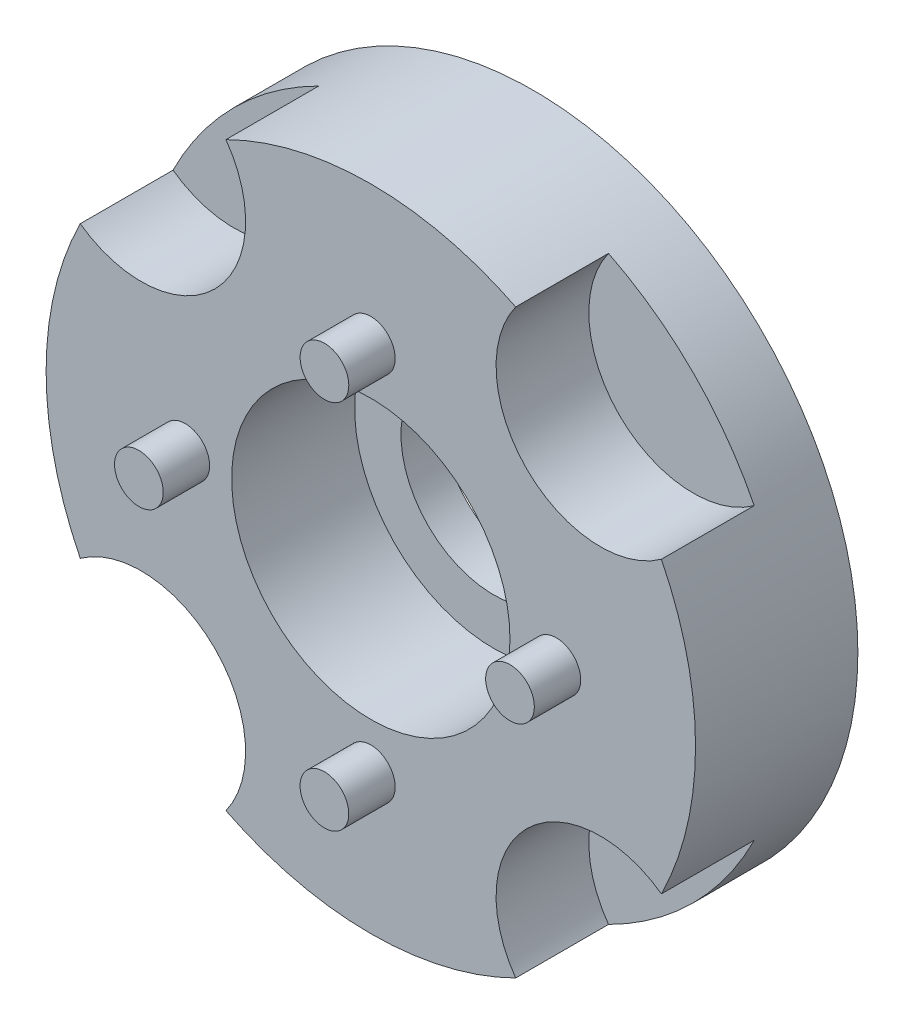
from build123d import *

# Parameters (mm, degrees)
SKIZZE1_R                            = 7
AUFSATZ_LINEAR_AUSTRAGEN1_DEPTH      = 3.5
SKIZZE2_R                            = 0.525
AUFSATZ_LINEAR_AUSTRAGEN2_DEPTH      = 1
KREISMUSTER1_COUNT                   = 4
SKIZZE3_R                            = 3
SCHNITT_LINEAR_AUSTRAGEN1_DEPTH      = 2
SCHNITT_LINEAR_AUSTRAGEN1_DEPTH_BACK = 2.65
SKIZZE4_R                            = 2
SCHNITT_LINEAR_AUSTRAGEN2_DEPTH      = 1.85
SKIZZE5_R                            = 2.25
SCHNITT_LINEAR_AUSTRAGEN3_DEPTH      = 2
KREISMUSTER2_COUNT                   = 4


with BuildPart() as part:
    # Skizze1 → Aufsatz-Linear austragen1 (new body)
    with BuildSketch(Plane.XY):
        Circle(SKIZZE1_R)
    extrude(amount=AUFSATZ_LINEAR_AUSTRAGEN1_DEPTH)

    # Skizze2 → Aufsatz-Linear austragen2 (add)
    with BuildSketch(Plane.XY.offset(3.5)):
        with Locations((0, 4)):
            Circle(SKIZZE2_R)
    aufsatz_linear_austragen2 = extrude(amount=AUFSATZ_LINEAR_AUSTRAGEN2_DEPTH)

    # Kreismuster1: Aufsatz-Linear austragen2 ×4 about axis
    kreismuster1_axis = Axis((0, 0, 0), (0, 0, 1))
    for i in range(1, KREISMUSTER1_COUNT):
        add(aufsatz_linear_austragen2.rotate(kreismuster1_axis, i * 360 / KREISMUSTER1_COUNT))

    # Skizze3 → Schnitt-Linear austragen1 (cut, two sides)
    with BuildSketch(Plane.XY.offset(3.5)) as schnitt_linear_austragen1_sk:
        Circle(SKIZZE3_R)
    extrude(amount=SCHNITT_LINEAR_AUSTRAGEN1_DEPTH, mode=Mode.SUBTRACT)
    extrude(schnitt_linear_austragen1_sk.sketch, amount=-SCHNITT_LINEAR_AUSTRAGEN1_DEPTH_BACK, mode=Mode.SUBTRACT)

    # Skizze4 → Schnitt-Linear austragen2 (cut, through all)
    with BuildSketch(Plane.XY.offset(0.85)):
        Circle(SKIZZE4_R)
    extrude(amount=-SCHNITT_LINEAR_AUSTRAGEN2_DEPTH, mode=Mode.SUBTRACT)

    # Skizze5 → Schnitt-Linear austragen3 (cut)
    with BuildSketch(Plane.XY.offset(3.5)):
        with Locations((-4.949747468, 4.949747468)):
            Circle(SKIZZE5_R)
    schnitt_linear_austragen3 = extrude(amount=-SCHNITT_LINEAR_AUSTRAGEN3_DEPTH, mode=Mode.SUBTRACT)

    # Kreismuster2: Schnitt-Linear austragen3 ×4 about axis
    kreismuster2_axis = Axis((0, 0, 0), (0, 0, 1))
    for i in range(1, KREISMUSTER2_COUNT):
        add(schnitt_linear_austragen3.rotate(kreismuster2_axis, i * 360 / KREISMUSTER2_COUNT), mode=Mode.SUBTRACT)


solid = part.part
